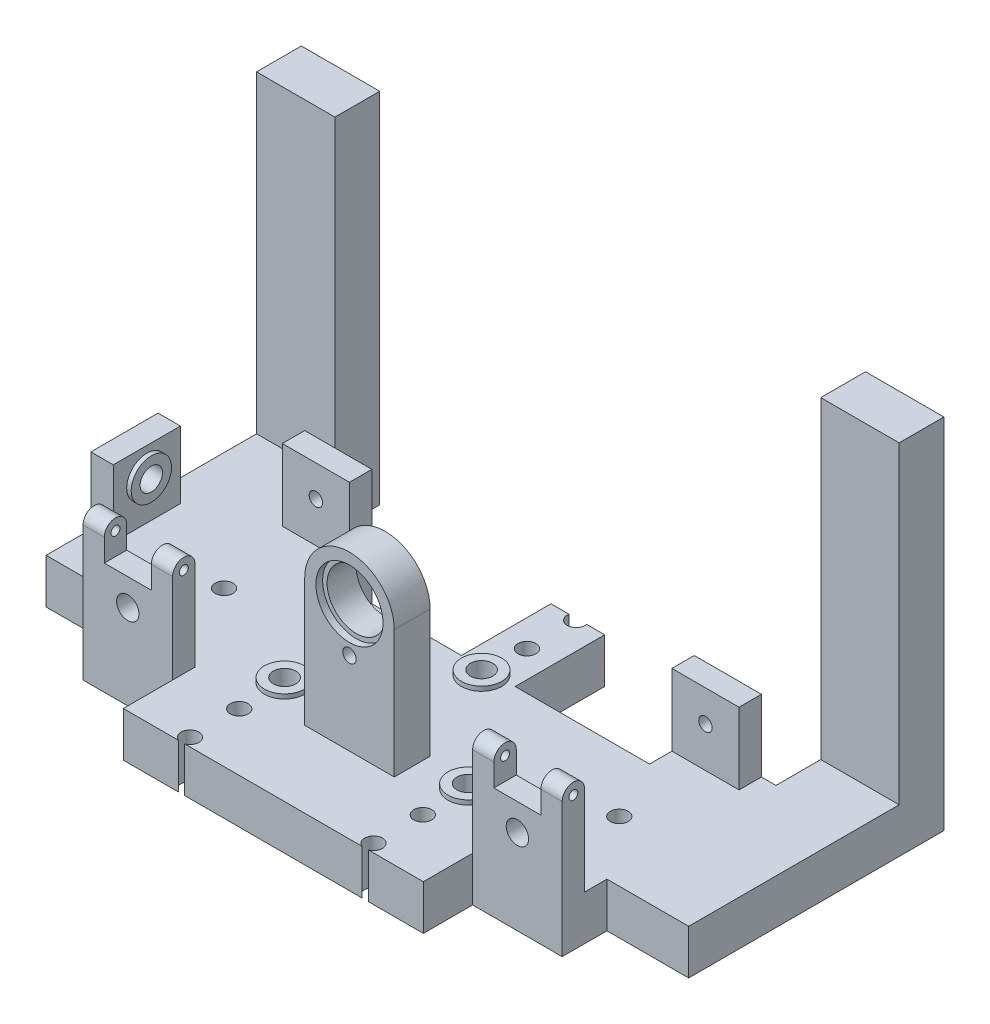
from build123d import *

# Parameters (mm, degrees)
EXTRUDE_1_DEPTH          = 20
SKETCH_3_W               = 10
SKETCH_3_H               = 30
EXTRUDE_2_DEPTH          = 30
SKETCH_5_W               = 40
SKETCH_5_H               = 10
EXTRUDE_3_DEPTH          = 30
SKETCH_2_R               = 5
CUT_EXTRUDE_1_DEPTH      = 13
CUT_EXTRUDE_2_REACH      = 12
SKETCH_4_R               = 5
CUT_EXTRUDE_3_REACH      = 34
SKETCH_6_R               = 5
SKETCH_7_R               = 9
SKETCH_7_R_2             = 5
EXTRUDE_4_DEPTH          = 2
SKETCH_8_R               = 9
SKETCH_8_R_2             = 5
EXTRUDE_5_DEPTH          = 2
SKETCH_9_R               = 9
SKETCH_9_R_2             = 5
EXTRUDE_6_DEPTH          = 2
SKETCH_11_W              = 40
SKETCH_11_H              = 16
EXTRUDE_7_DEPTH          = 57
SKETCH_12_W              = 20
SKETCH_12_H              = 16
REVOLVE_1_ANGLE          = 180
SKETCH_13_R              = 15
CUT_EXTRUDE_5_DEPTH      = 35
CUT_EXTRUDE_5_DEPTH_BACK = 3
CUT_EXTRUDE_6_REACH      = 101
SKETCH_14_R              = 13
SKETCH_15_R              = 3
CUT_EXTRUDE_7_DEPTH      = 12
SKETCH_10_R              = 4
CUT_EXTRUDE_4_DEPTH      = 21
EXTRUDE_8_DEPTH          = 40
SKETCH_17_W              = 10
SKETCH_17_H              = 21
CUT_EXTRUDE_8_DEPTH      = 15
SKETCH_18_R              = 2
CUT_EXTRUDE_9_DEPTH      = 40
SKETCH_19_W              = 30
SKETCH_19_H              = 10
EXTRUDE_9_DEPTH          = 32
SKETCH_20_R              = 3
CUT_EXTRUDE_10_DEPTH     = 20
SKETCH_21_W              = 35
SKETCH_21_H              = 20
EXTRUDE_10_DEPTH         = 40
SKETCH_22_W              = 35
SKETCH_22_H              = 20
EXTRUDE_11_DEPTH         = 140


with BuildPart() as part:
    # 草图1 → 凸台-拉伸1 (new body)
    with BuildSketch(Plane(origin=(0, 0, 0), x_dir=(1, 0, 0), z_dir=(0, 1, 0))):
        Polygon((-67, 0), (67, 0), (67, 22), (107, 22), (107, 42), (143.5, 42), (143.5, 116), (72, 116), (72, 96), (12, 96), (12, 136), (-12, 136), (-12, 96), (-72, 96), (-72, 116), (-143.5, 116), (-143.5, 42), (-107, 42), (-107, 22), (-67, 22), align=None)
    extrude(amount=EXTRUDE_1_DEPTH)

    # 草图3 → 凸台-拉伸2 (add)
    with BuildSketch(Plane(origin=(0, 20, 0), x_dir=(1, 0, 0), z_dir=(0, 1, 0))):
        with Locations((-138.5, 77)):
            Rectangle(SKETCH_3_W, SKETCH_3_H)
    extrude(amount=EXTRUDE_2_DEPTH)

    # 草图5 → 凸台-拉伸3 (add)
    with BuildSketch(Plane(origin=(0, 20, 0), x_dir=(1, 0, 0), z_dir=(0, 1, 0))):
        with Locations((-87, 27)):
            Rectangle(SKETCH_5_W, SKETCH_5_H)
        with Locations((87, 27)):
            Rectangle(SKETCH_5_W, SKETCH_5_H)
    extrude(amount=EXTRUDE_3_DEPTH)

    # 草图2 → 切除-拉伸1 (cut)
    with BuildSketch(Plane(origin=(0, 20, 0), x_dir=(1, 0, 0), z_dir=(0, 1, 0))):
        with Locations((0, 93)):
            Circle(SKETCH_2_R)
        with Locations((-41, 46)):
            Circle(SKETCH_2_R)
        with Locations((41, 46)):
            Circle(SKETCH_2_R)
    extrude(amount=-CUT_EXTRUDE_1_DEPTH, mode=Mode.SUBTRACT)

    # 草图4 → 切除-拉伸2 (cut, up to next)
    with BuildSketch(Plane(origin=(-133.5, 0, 0), x_dir=(0, 0, -1), z_dir=(1, 0, 0)), mode=Mode.PRIVATE) as cut_extrude_2_sk1:
        with Locations((77, 38)):
            Circle(SKETCH_4_R)
    cut_extrude_2_tool1 = extrude(cut_extrude_2_sk1.sketch, amount=-CUT_EXTRUDE_2_REACH, mode=Mode.PRIVATE) & part.part
    add(cut_extrude_2_tool1.solids().sort_by_distance((-133.5, 38, -77))[0], mode=Mode.SUBTRACT)

    # 草图6 → 切除-拉伸3 (cut, up to next)
    with BuildSketch(Plane(origin=(0, 0, -32), x_dir=(-1, 0, 0), z_dir=(0, 0, -1)), mode=Mode.PRIVATE) as cut_extrude_3_sk1:
        with Locations((87, 38)):
            Circle(SKETCH_6_R)
    cut_extrude_3_tool1 = extrude(cut_extrude_3_sk1.sketch, amount=-CUT_EXTRUDE_3_REACH, mode=Mode.PRIVATE) & part.part
    add(cut_extrude_3_tool1.solids().sort_by_distance((-87, 38, -32))[0], mode=Mode.SUBTRACT)
    # 草图6 → 切除-拉伸3 (cut, up to next)
    with BuildSketch(Plane(origin=(0, 0, -32), x_dir=(-1, 0, 0), z_dir=(0, 0, -1)), mode=Mode.PRIVATE) as cut_extrude_3_sk2:
        with Locations((-87, 38)):
            Circle(SKETCH_6_R)
    cut_extrude_3_tool2 = extrude(cut_extrude_3_sk2.sketch, amount=-CUT_EXTRUDE_3_REACH, mode=Mode.PRIVATE) & part.part
    add(cut_extrude_3_tool2.solids().sort_by_distance((87, 38, -32))[0], mode=Mode.SUBTRACT)

    # 草图7 → 凸台-拉伸4 (add)
    with BuildSketch(Plane(origin=(-133.5, 0, 0), x_dir=(0, 0, -1), z_dir=(1, 0, 0))):
        with Locations((77, 38)):
            Circle(SKETCH_7_R)
        with Locations((77, 38)):
            Circle(SKETCH_7_R_2, mode=Mode.SUBTRACT)
    extrude(amount=EXTRUDE_4_DEPTH)

    # 草图8 → 凸台-拉伸5 (add)
    with BuildSketch(Plane(origin=(0, 0, -32), x_dir=(-1, 0, 0), z_dir=(0, 0, -1))):
        with Locations((-87, 38)):
            Circle(SKETCH_8_R)
        with Locations((-87, 38)):
            Circle(SKETCH_8_R_2, mode=Mode.SUBTRACT)
        with Locations((87, 38)):
            Circle(SKETCH_8_R)
        with Locations((87, 38)):
            Circle(SKETCH_8_R_2, mode=Mode.SUBTRACT)
    extrude(amount=EXTRUDE_5_DEPTH)

    # 草图9 → 凸台-拉伸6 (add)
    with BuildSketch(Plane(origin=(0, 20, 0), x_dir=(1, 0, 0), z_dir=(0, 1, 0))):
        with Locations((-41, 46)):
            Circle(SKETCH_9_R)
        with Locations((-41, 46)):
            Circle(SKETCH_9_R_2, mode=Mode.SUBTRACT)
        with Locations((0, 93)):
            Circle(SKETCH_9_R)
        with Locations((0, 93)):
            Circle(SKETCH_9_R_2, mode=Mode.SUBTRACT)
        with Locations((41, 46)):
            Circle(SKETCH_9_R)
        with Locations((41, 46)):
            Circle(SKETCH_9_R_2, mode=Mode.SUBTRACT)
    extrude(amount=EXTRUDE_6_DEPTH)

    # 草图11 → 凸台-拉伸7 (add)
    with BuildSketch(Plane(origin=(0, 20, 0), x_dir=(1, 0, 0), z_dir=(0, 1, 0))):
        with Locations((0, 42)):
            Rectangle(SKETCH_11_W, SKETCH_11_H)
    extrude(amount=EXTRUDE_7_DEPTH)

    # 草图12 → 旋转1 (revolve)
    with BuildSketch(Plane(origin=(0, 77, 0), x_dir=(1, 0, 0), z_dir=(0, 1, 0))):
        with Locations((-10, 42)):
            Rectangle(SKETCH_12_W, SKETCH_12_H)
    revolve(axis=Axis((0, 77, -50), (0, 0, -1)), revolution_arc=REVOLVE_1_ANGLE)

    # 草图13 → 切除-拉伸5 (cut, two sides)
    with BuildSketch(Plane.XY.offset(-34)) as cut_extrude_5_sk:
        with Locations((0, 77)):
            Circle(SKETCH_13_R)
    extrude(amount=CUT_EXTRUDE_5_DEPTH, mode=Mode.SUBTRACT)
    extrude(cut_extrude_5_sk.sketch, amount=-CUT_EXTRUDE_5_DEPTH_BACK, mode=Mode.SUBTRACT)

    # 草图14 → 切除-拉伸6 (cut, up to next)
    with BuildSketch(Plane.XY.offset(-37), mode=Mode.PRIVATE) as cut_extrude_6_sk1:
        with Locations((0, 77)):
            Circle(SKETCH_14_R)
    cut_extrude_6_tool1 = extrude(cut_extrude_6_sk1.sketch, amount=-CUT_EXTRUDE_6_REACH, mode=Mode.PRIVATE) & part.part
    add(cut_extrude_6_tool1.solids().sort_by_distance((0, 77, -37))[0], mode=Mode.SUBTRACT)

    # 草图15 → 切除-拉伸7 (cut)
    with BuildSketch(Plane.XY.offset(-34)):
        with Locations((0, 57)):
            Circle(SKETCH_15_R)
    extrude(amount=-CUT_EXTRUDE_7_DEPTH, mode=Mode.SUBTRACT)

    # 草图10 → 切除-拉伸4 (cut, through all)
    with BuildSketch(Plane(origin=(0, 20, 0), x_dir=(1, 0, 0), z_dir=(0, 1, 0))):
        with Locations((-41, 25.75)):
            Circle(SKETCH_10_R)
        with Locations((41, 25.75)):
            Circle(SKETCH_10_R)
        with Locations((-41, 3.75)):
            Circle(SKETCH_10_R)
        with Locations((41, 3.75)):
            Circle(SKETCH_10_R)
        with Locations((-91, 69)):
            Circle(SKETCH_10_R)
        with Locations((0, 113.25)):
            Circle(SKETCH_10_R)
        with Locations((0, 135.25)):
            Circle(SKETCH_10_R)
        with Locations((85.5, 69)):
            Circle(SKETCH_10_R)
    extrude(amount=-CUT_EXTRUDE_4_DEPTH, mode=Mode.SUBTRACT)

    # 草图16 → 凸台-拉伸8 (add)
    with BuildSketch(Plane(origin=(107, 0, 0), x_dir=(0, 0, -1), z_dir=(1, 0, 0))):
        with BuildLine():
            Line((22, 50), (22, 60))
            ThreePointArc((22, 60), (27, 65), (32, 60))
            Line((32, 60), (32, 50))
            Line((32, 50), (22, 50))
        make_face()
    extrude_8 = extrude(amount=-EXTRUDE_8_DEPTH)

    # 草图17 → 切除-拉伸8 (cut)
    with BuildSketch(Plane(origin=(45, 50, 0), x_dir=(0, 0, -1), z_dir=(0, -1, 0))):
        with Locations((27, 42)):
            Rectangle(SKETCH_17_W, SKETCH_17_H)
    cut_extrude_8 = extrude(amount=-CUT_EXTRUDE_8_DEPTH, mode=Mode.SUBTRACT)

    # 草图18 → 切除-拉伸9 (cut)
    with BuildSketch(Plane(origin=(107, 0, 0), x_dir=(0, 0, -1), z_dir=(1, 0, 0))):
        with Locations((27, 60)):
            Circle(SKETCH_18_R)
    cut_extrude_9 = extrude(amount=-CUT_EXTRUDE_9_DEPTH, mode=Mode.SUBTRACT)

    # 镜向1: 凸台-拉伸8, 切除-拉伸8, 切除-拉伸9 across plane
    add(extrude_8.mirror(Plane(origin=(0, 0, 0), x_dir=(0, 0, 1), z_dir=(1, 0, 0))))
    add(cut_extrude_8.mirror(Plane(origin=(0, 0, 0), x_dir=(0, 0, 1), z_dir=(1, 0, 0))), mode=Mode.SUBTRACT)
    add(cut_extrude_9.mirror(Plane(origin=(0, 0, 0), x_dir=(0, 0, 1), z_dir=(1, 0, 0))), mode=Mode.SUBTRACT)

    # 草图19 → 凸台-拉伸9 (add)
    with BuildSketch(Plane(origin=(0, 20, 0), x_dir=(1, 0, 0), z_dir=(0, 1, 0))):
        with Locations((-87, 111)):
            Rectangle(SKETCH_19_W, SKETCH_19_H)
        with Locations((87, 111)):
            Rectangle(SKETCH_19_W, SKETCH_19_H)
    extrude(amount=EXTRUDE_9_DEPTH)

    # 草图20 → 切除-拉伸10 (cut)
    with BuildSketch(Plane(origin=(0, 0, -116), x_dir=(-1, 0, 0), z_dir=(0, 0, -1))):
        with Locations((-87, 38)):
            Circle(SKETCH_20_R)
        with Locations((87, 38)):
            Circle(SKETCH_20_R)
    extrude(amount=-CUT_EXTRUDE_10_DEPTH, mode=Mode.SUBTRACT)

    # 草图21 → 凸台-拉伸10 (add)
    with BuildSketch(Plane(origin=(0, 0, -116), x_dir=(-1, 0, 0), z_dir=(0, 0, -1))):
        with Locations((-126, 10)):
            Rectangle(SKETCH_21_W, SKETCH_21_H)
        with Locations((126, 10)):
            Rectangle(SKETCH_21_W, SKETCH_21_H)
    extrude(amount=EXTRUDE_10_DEPTH)

    # 草图22 → 凸台-拉伸11 (add)
    with BuildSketch(Plane(origin=(0, 20, 0), x_dir=(1, 0, 0), z_dir=(0, 1, 0))):
        with Locations((-126, 146)):
            Rectangle(SKETCH_22_W, SKETCH_22_H)
        with Locations((126, 146)):
            Rectangle(SKETCH_22_W, SKETCH_22_H)
    extrude(amount=EXTRUDE_11_DEPTH)


solid = part.part
